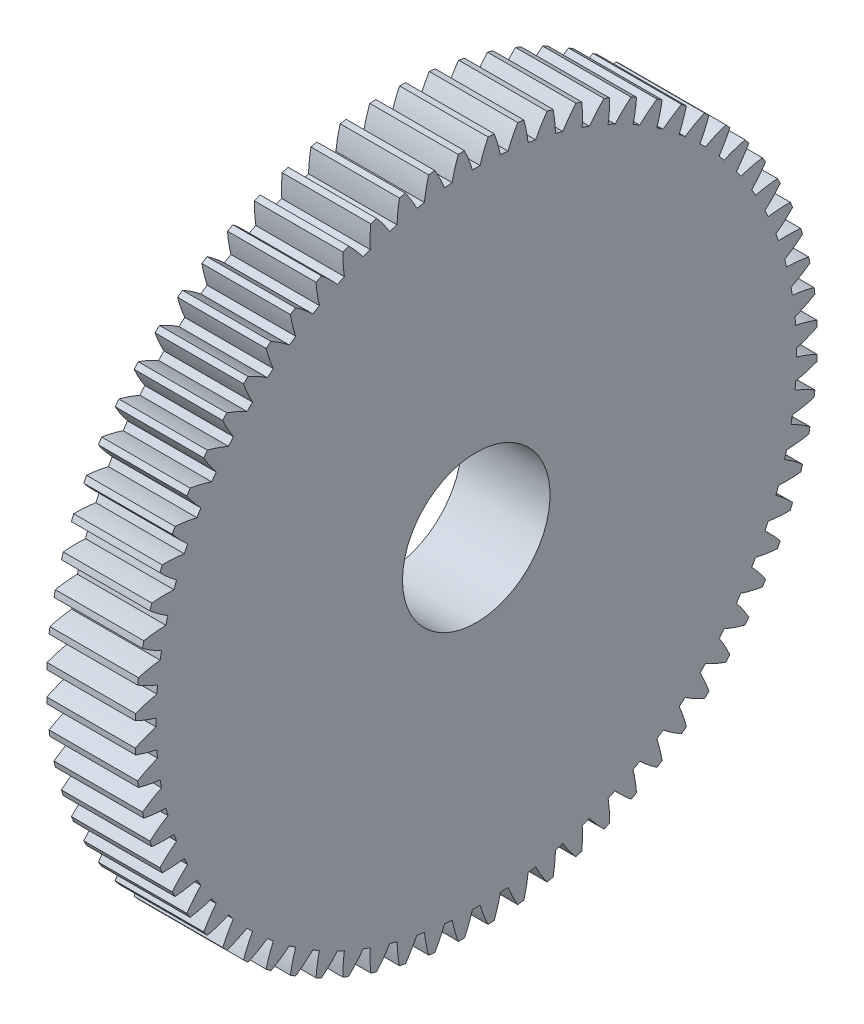
from build123d import *

# Parameters (mm, degrees)
BASPROSKE_W     = 7.62
BASPROSKE_H     = 29.36875
TOOTHCUT_DEPTH  = 43.226903191
TEETHCUTS_COUNT = 72
TEETHCUTS_ANGLE = 355
BORSKE_R        = 6.35
BORE_DEPTH      = 50.8000508


with BuildPart() as part:
    # BasProSke → Base-Revolve (revolve)
    with BuildSketch(Plane(origin=(0, 0, 0), x_dir=(1, 0, 0), z_dir=(0, 1, 0)), mode=Mode.PRIVATE) as base_revolve_sk:
        with Locations((3.81, 14.684375)):
            Rectangle(BASPROSKE_W, BASPROSKE_H)
    revolve(base_revolve_sk.sketch.rotate(Axis((-10, 0, 0), (1, 0, 0)), 180), axis=Axis((-10, 0, 0), (1, 0, 0)))

    # TooCutSke → ToothCut (cut, through all)
    with BuildSketch(Plane(origin=(0, 0, 0), x_dir=(0, 0, -1), z_dir=(1, 0, 0))):
        with BuildLine():
            ThreePointArc((0.330463748, 27.569719523), (0, 27.5717), (-0.330463748, 27.569719523))
            ThreePointArc((-0.330463748, 27.569719523), (-0.642071496, 28.487757085), (-1.030355266, 29.376085891))
            ThreePointArc((-1.030355266, 29.376085891), (0, 29.39415), (1.030355266, 29.376085891))
            ThreePointArc((1.030355266, 29.376085891), (0.642071496, 28.487757085), (0.330463748, 27.569719523))
        make_face()
    toothcut = extrude(amount=TOOTHCUT_DEPTH, mode=Mode.SUBTRACT)

    # TeethCuts: ToothCut ×72 about axis
    teethcuts_axis = Axis((-10, 0, 0), (1, 0, 0))
    for i in range(1, TEETHCUTS_COUNT):
        add(toothcut.rotate(teethcuts_axis, i * TEETHCUTS_ANGLE / (TEETHCUTS_COUNT - 1)), mode=Mode.SUBTRACT)

    # BorSke → Bore (cut, symmetric)
    with BuildSketch(Plane(origin=(0, 0, 0), x_dir=(0, 0, -1), z_dir=(1, 0, 0))):
        with Locations(Location((0, 0, 0), (0, 0, 180))):
            Circle(BORSKE_R)
    extrude(amount=BORE_DEPTH, both=True, mode=Mode.SUBTRACT)


solid = part.part
